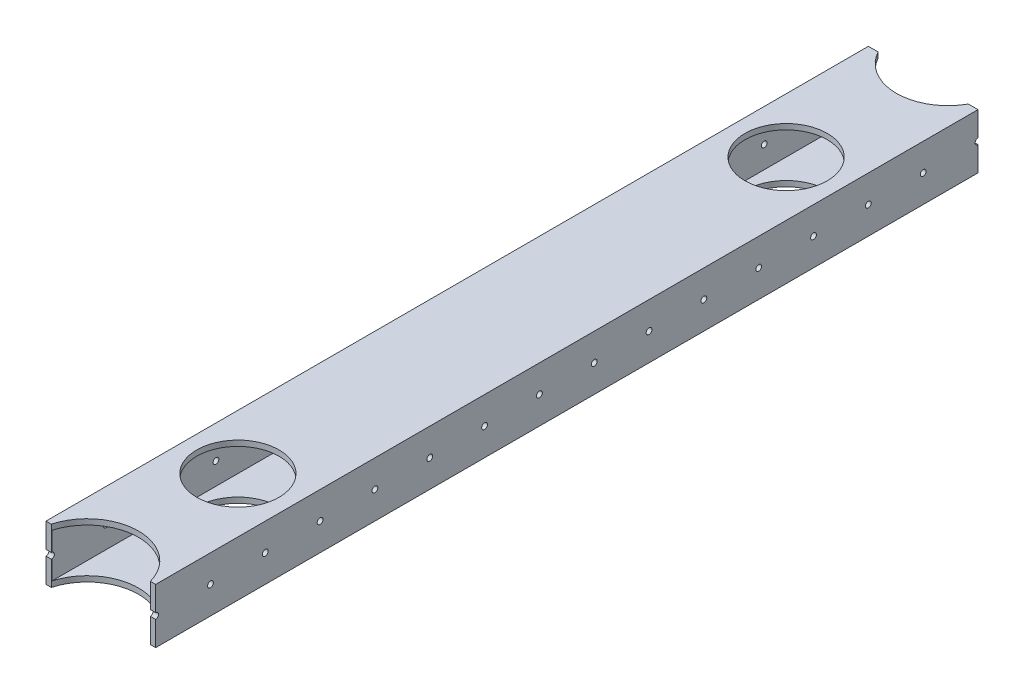
from build123d import *

# Parameters (mm, degrees)
SKETCH1_W           = 50.8
SKETCH1_H           = 25.4
SKETCH1_W_2         = 45.72
SKETCH1_H_2         = 20.32
EXTRUDE_THIN1_DEPTH = 398.78
SKETCH2_R           = 1.3462
CUT_EXTRUDE1_DEPTH  = 51.8
LPATTERN1_COUNT     = 19
LPATTERN1_PITCH     = 25.4
CUT_EXTRUDE2_DEPTH  = 26.4
SKETCH4_R           = 19.05
CUT_EXTRUDE3_DEPTH  = 26.4000001


with BuildPart() as part:
    # Sketch1 → Extrude-Thin1 (new body)
    with BuildSketch(Plane.XY):
        Rectangle(SKETCH1_W, SKETCH1_H)
        Rectangle(SKETCH1_W_2, SKETCH1_H_2, mode=Mode.SUBTRACT)
    extrude(amount=EXTRUDE_THIN1_DEPTH)

    # Sketch2 → Cut-Extrude1 (cut, through all)
    with BuildSketch(Plane(origin=(25.4, 0, 0), x_dir=(0, 0, -1), z_dir=(1, 0, 0))):
        with Locations((-392.43, 0)):
            Circle(SKETCH2_R)
    cut_extrude1 = extrude(amount=-CUT_EXTRUDE1_DEPTH, mode=Mode.SUBTRACT)

    # LPattern1: Cut-Extrude1 ×19
    with Locations(*[(0, 0, -i * LPATTERN1_PITCH) for i in range(1, LPATTERN1_COUNT)]):
        add(cut_extrude1, mode=Mode.SUBTRACT)

    # Sketch3 → Cut-Extrude2 (cut, through all)
    with BuildSketch(Plane(origin=(0, 12.7, 0), x_dir=(1, 0, 0), z_dir=(0, 1, 0))):
        with BuildLine():
            ThreePointArc((23.8125, -398.78), (23.595945628, -395.57586109), (22.950221268, -392.43))
            ThreePointArc((22.950221268, -392.43), (0, -374.9675), (-22.950221268, -392.43))
            ThreePointArc((-22.950221268, -392.43), (-23.595945628, -395.57586109), (-23.8125, -398.78))
            Line((-23.8125, -398.78), (23.8125, -398.78))
        make_face()
        with BuildLine():
            ThreePointArc((-23.8125, -398.78), (0, -422.5925), (23.8125, -398.78))
            Line((23.8125, -398.78), (-23.8125, -398.78))
        make_face()
        with BuildLine():
            Line((25.4, -398.78), (25.4, -392.43))
            Line((25.4, -392.43), (22.950221268, -392.43))
            ThreePointArc((22.950221268, -392.43), (23.595945628, -395.57586109), (23.8125, -398.78))
            Line((23.8125, -398.78), (25.4, -398.78))
        make_face()
        with BuildLine():
            ThreePointArc((-23.8125, -398.78), (-23.595945628, -395.57586109), (-22.950221268, -392.43))
            Line((-22.950221268, -392.43), (-25.4, -392.43))
            Line((-25.4, -392.43), (-25.4, -398.78))
            Line((-25.4, -398.78), (-23.8125, -398.78))
        make_face()
        with BuildLine():
            ThreePointArc((-20.88995587, -11.43), (0, -23.8125), (20.88995587, -11.43))
            ThreePointArc((20.88995587, -11.43), (23.07029725, -5.898859301), (23.8125, 0))
            Line((23.8125, 0), (-23.8125, 0))
            ThreePointArc((-23.8125, 0), (-23.07029725, -5.898859301), (-20.88995587, -11.43))
        make_face()
        with BuildLine():
            Line((-23.8125, 0), (23.8125, 0))
            ThreePointArc((23.8125, 0), (0, 23.8125), (-23.8125, 0))
        make_face()
        with BuildLine():
            Line((-25.4, -11.43), (-20.88995587, -11.43))
            ThreePointArc((-20.88995587, -11.43), (-23.07029725, -5.898859301), (-23.8125, 0))
            Line((-23.8125, 0), (-25.4, 0))
            Line((-25.4, 0), (-25.4, -11.43))
        make_face()
        with BuildLine():
            Line((20.88995587, -11.43), (25.4, -11.43))
            Line((25.4, -11.43), (25.4, 0))
            Line((25.4, 0), (23.8125, 0))
            ThreePointArc((23.8125, 0), (23.07029725, -5.898859301), (20.88995587, -11.43))
        make_face()
    extrude(amount=-CUT_EXTRUDE2_DEPTH, mode=Mode.SUBTRACT)

    # Sketch4 → Cut-Extrude3 (cut, through all)
    with BuildSketch(Plane(origin=(0, 12.7, 0), x_dir=(1, 0, 0), z_dir=(0, 1, 0))):
        with Locations((0, -328.93)):
            Circle(SKETCH4_R)
        with Locations((0, -74.93)):
            Circle(SKETCH4_R)
    extrude(amount=-CUT_EXTRUDE3_DEPTH, mode=Mode.SUBTRACT)


solid = part.part
